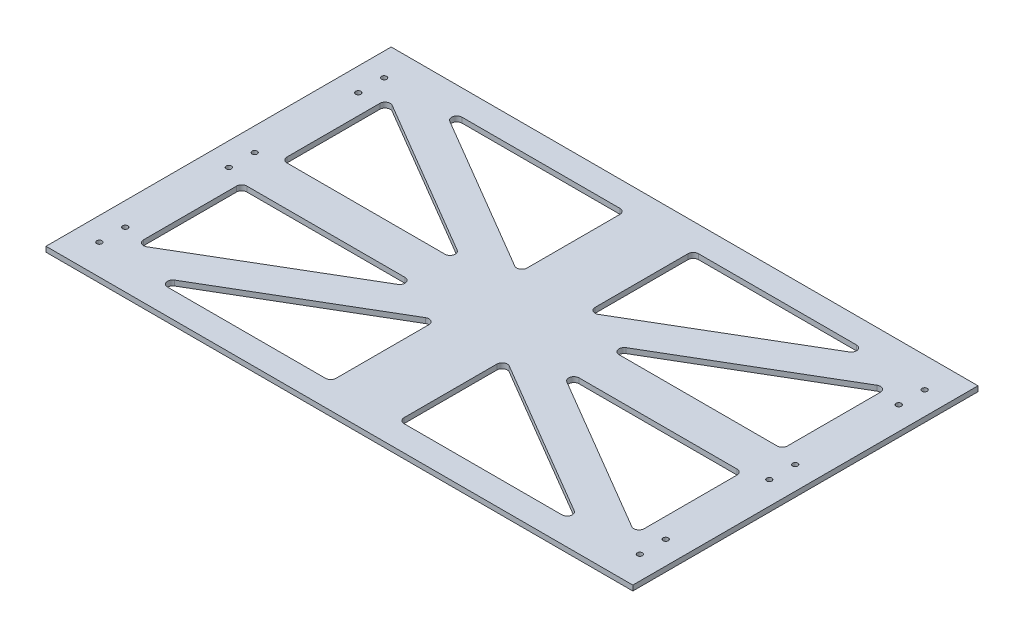
from build123d import *

# Parameters (mm, degrees)
SKETCH1_W                      = 170
SKETCH1_H                      = 200
BOSS_EXTRUDE1_DEPTH            = 3
FILLET1_R                      = 3
F_3_0MM_DOWEL_HOLE1_AT_2_COUNT = 2
F_3_0MM_DOWEL_HOLE1_AT_2_PITCH = 15
F_3_0MM_DOWEL_HOLE1_AT_3_COUNT = 2
F_3_0MM_DOWEL_HOLE1_AT_3_PITCH = 75
F_3_0MM_DOWEL_HOLE1_AT_4_COUNT = 2
F_3_0MM_DOWEL_HOLE1_AT_4_PITCH = 90
F_3_0MM_DOWEL_HOLE1_AT_5_COUNT = 2
F_3_0MM_DOWEL_HOLE1_AT_5_PITCH = 60
F_3_0MM_DOWEL_HOLE1_AT_6_COUNT = 2
F_3_0MM_DOWEL_HOLE1_AT_6_PITCH = 75
FILLET1_OF_MIRROR1_R           = 3


with BuildPart() as part:
    # Sketch1 → Boss-Extrude1 (new body)
    with BuildSketch(Plane(origin=(0, 0, 0), x_dir=(1, 0, 0), z_dir=(0, 1, 0))):
        with Locations((-85, 0)):
            Rectangle(SKETCH1_W, SKETCH1_H)
        Polygon((-19.723082923, 85.294117647), (-19.723082923, 23.203626969), (-125.276917077, 85.294117647), align=None, mode=Mode.SUBTRACT)
        Polygon((-39.446165847, 11.601813484), (-145, 11.601813484), (-145, 73.692304163), align=None, mode=Mode.SUBTRACT)
        Polygon((-125.276917077, -85.294117647), (-19.723082923, -23.203626969), (-19.723082923, -85.294117647), align=None, mode=Mode.SUBTRACT)
        Polygon((-145, -11.601813484), (-39.446165847, -11.601813484), (-145, -73.692304163), align=None, mode=Mode.SUBTRACT)
    boss_extrude1 = extrude(amount=BOSS_EXTRUDE1_DEPTH)

    # Fillet1
    fillet1_edges = [part.edges().sort_by_distance(p)[0] for p in [
        (-19.723082923, 1.5, -23.203626969),
        (-19.723082923, 1.5, -85.294117647),
        (-125.276917077, 1.5, -85.294117647),
        (-39.446165847, 1.5, -11.601813484),
        (-145, 1.5, -73.692304163),
        (-145, 1.5, -11.601813484),
        (-39.446165847, 1.5, 11.601813484),
        (-145, 1.5, 11.601813484),
        (-145, 1.5, 73.692304163),
        (-19.723082923, 1.5, 23.203626969),
        (-125.276917077, 1.5, 85.294117647),
        (-19.723082923, 1.5, 85.294117647),
    ]]
    fillet(fillet1_edges, radius=FILLET1_R)

    # Sketch2 → Ø3.0mm Dowel Hole1 (revolve, cut)
    with BuildSketch(Plane(origin=(-156.575, 3, -7.5), x_dir=(0, 0, 1), z_dir=(1, 0, 0))):
        Polygon((0, 0), (0, 15.901290929), (1.5, 15), (1.5, 0), align=None)
    f_3_0mm_dowel_hole1 = revolve(axis=Axis((-156.575, 9.35, -7.5), (0, -1, 0)), mode=Mode.SUBTRACT)

    # Ø3.0mm Dowel Hole1 at 2: Ø3.0mm Dowel Hole1 ×2
    with Locations(*[(0, 0, i * F_3_0MM_DOWEL_HOLE1_AT_2_PITCH) for i in range(1, F_3_0MM_DOWEL_HOLE1_AT_2_COUNT)]):
        add(f_3_0mm_dowel_hole1, mode=Mode.SUBTRACT)

    # Ø3.0mm Dowel Hole1 at 3: Ø3.0mm Dowel Hole1 ×2
    with Locations(*[(0, 0, i * F_3_0MM_DOWEL_HOLE1_AT_3_PITCH) for i in range(1, F_3_0MM_DOWEL_HOLE1_AT_3_COUNT)]):
        add(f_3_0mm_dowel_hole1, mode=Mode.SUBTRACT)

    # Ø3.0mm Dowel Hole1 at 4: Ø3.0mm Dowel Hole1 ×2
    with Locations(*[(0, 0, i * F_3_0MM_DOWEL_HOLE1_AT_4_PITCH) for i in range(1, F_3_0MM_DOWEL_HOLE1_AT_4_COUNT)]):
        add(f_3_0mm_dowel_hole1, mode=Mode.SUBTRACT)

    # Ø3.0mm Dowel Hole1 at 5: Ø3.0mm Dowel Hole1 ×2
    with Locations(*[(0, 0, -i * F_3_0MM_DOWEL_HOLE1_AT_5_PITCH) for i in range(1, F_3_0MM_DOWEL_HOLE1_AT_5_COUNT)]):
        add(f_3_0mm_dowel_hole1, mode=Mode.SUBTRACT)

    # Ø3.0mm Dowel Hole1 at 6: Ø3.0mm Dowel Hole1 ×2
    with Locations(*[(0, 0, -i * F_3_0MM_DOWEL_HOLE1_AT_6_PITCH) for i in range(1, F_3_0MM_DOWEL_HOLE1_AT_6_COUNT)]):
        add(f_3_0mm_dowel_hole1, mode=Mode.SUBTRACT)

    # Mirror1: Boss-Extrude1, Ø3.0mm Dowel Hole1 across plane
    add(boss_extrude1.mirror(Plane(origin=(0, 0, 0), x_dir=(0, 0, 1), z_dir=(1, 0, 0))))
    add(f_3_0mm_dowel_hole1.mirror(Plane(origin=(0, 0, 0), x_dir=(0, 0, 1), z_dir=(1, 0, 0))), mode=Mode.SUBTRACT)

    # Mirror1 copy 1 sketch → Mirror1 copy 1 (revolve, cut)
    with BuildSketch(Plane(origin=(156.575, 3, 7.5), x_dir=(0, 0, 1), z_dir=(-1, 0, 0))):
        Polygon((0, 0), (0, -15.901290929), (1.5, -15), (1.5, 0), align=None)
    revolve(axis=Axis((156.575, 9.35, 7.5), (0, 1, 0)), mode=Mode.SUBTRACT)

    # Mirror1 copy 2 sketch → Mirror1 copy 2 (revolve, cut)
    with BuildSketch(Plane(origin=(156.575, 3, 67.5), x_dir=(0, 0, 1), z_dir=(-1, 0, 0))):
        Polygon((0, 0), (0, -15.901290929), (1.5, -15), (1.5, 0), align=None)
    revolve(axis=Axis((156.575, 9.35, 67.5), (0, 1, 0)), mode=Mode.SUBTRACT)

    # Mirror1 copy 3 sketch → Mirror1 copy 3 (revolve, cut)
    with BuildSketch(Plane(origin=(156.575, 3, 82.5), x_dir=(0, 0, 1), z_dir=(-1, 0, 0))):
        Polygon((0, 0), (0, -15.901290929), (1.5, -15), (1.5, 0), align=None)
    revolve(axis=Axis((156.575, 9.35, 82.5), (0, 1, 0)), mode=Mode.SUBTRACT)

    # Mirror1 copy 4 sketch → Mirror1 copy 4 (revolve, cut)
    with BuildSketch(Plane(origin=(156.575, 3, -67.5), x_dir=(0, 0, 1), z_dir=(-1, 0, 0))):
        Polygon((0, 0), (0, -15.901290929), (1.5, -15), (1.5, 0), align=None)
    revolve(axis=Axis((156.575, 9.35, -67.5), (0, 1, 0)), mode=Mode.SUBTRACT)

    # Mirror1 copy 5 sketch → Mirror1 copy 5 (revolve, cut)
    with BuildSketch(Plane(origin=(156.575, 3, -82.5), x_dir=(0, 0, 1), z_dir=(-1, 0, 0))):
        Polygon((0, 0), (0, -15.901290929), (1.5, -15), (1.5, 0), align=None)
    revolve(axis=Axis((156.575, 9.35, -82.5), (0, 1, 0)), mode=Mode.SUBTRACT)

    # Fillet1 of Mirror1
    fillet1_of_mirror1_edges = [part.edges().sort_by_distance(p)[0] for p in [
        (19.723082923, 1.5, -23.203626969),
        (19.723082923, 1.5, -85.294117647),
        (125.276917077, 1.5, -85.294117647),
        (39.446165847, 1.5, -11.601813484),
        (145, 1.5, -73.692304163),
        (145, 1.5, -11.601813484),
        (39.446165847, 1.5, 11.601813484),
        (145, 1.5, 11.601813484),
        (145, 1.5, 73.692304163),
        (19.723082923, 1.5, 23.203626969),
        (125.276917077, 1.5, 85.294117647),
        (19.723082923, 1.5, 85.294117647),
    ]]
    fillet(fillet1_of_mirror1_edges, radius=FILLET1_OF_MIRROR1_R)


solid = part.part
